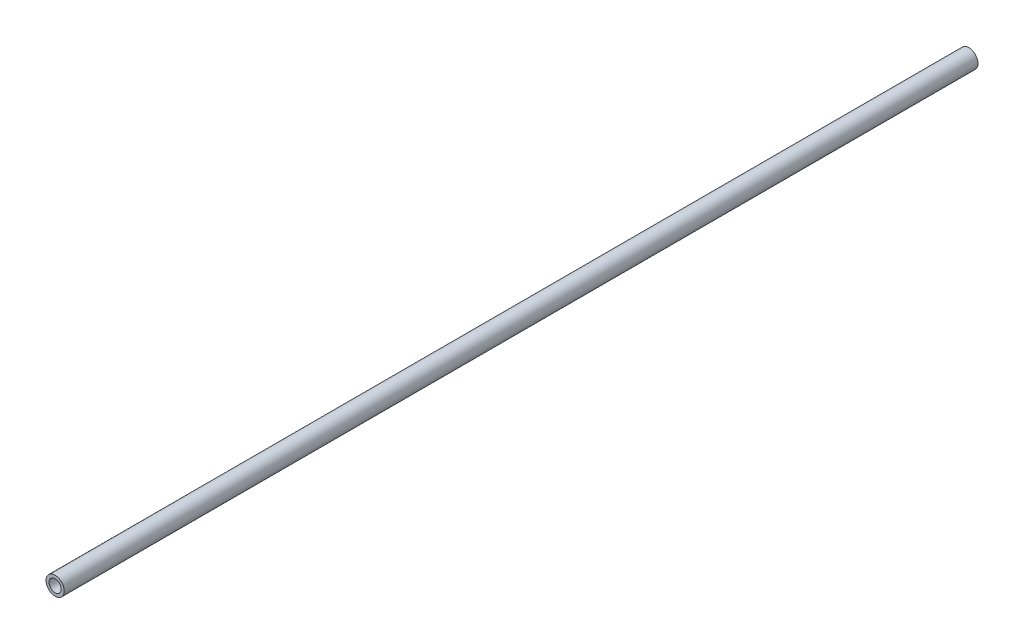
from build123d import *

# Parameters (mm, degrees)
SKETCH2_R           = 3
SKETCH2_R_2         = 2
BOSS_EXTRUDE1_DEPTH = 300


with BuildPart() as part:
    # Sketch2 → Boss-Extrude1 (new body)
    with BuildSketch(Plane.XY):
        Circle(SKETCH2_R)
        Circle(SKETCH2_R_2, mode=Mode.SUBTRACT)
    extrude(amount=BOSS_EXTRUDE1_DEPTH)


solid = part.part
